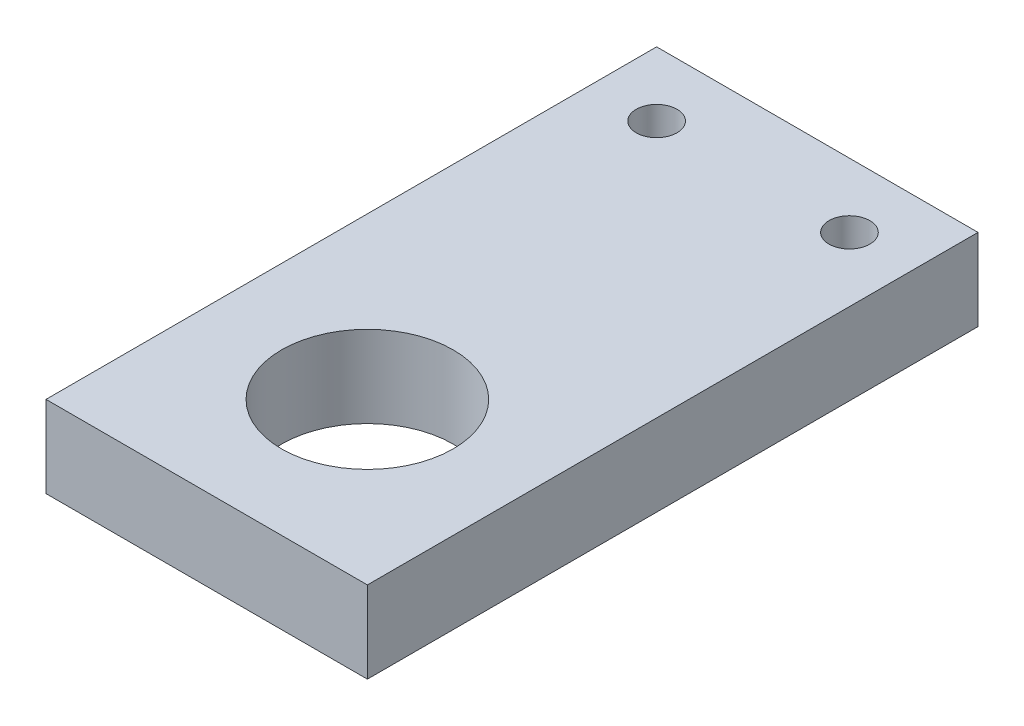
from build123d import *

# Parameters (mm, degrees)
SKETCH1_W           = 25
SKETCH1_H           = 47.5
SKETCH1_R           = 6.675
BOSS_EXTRUDE1_DEPTH = 6.35
CUT_EXTRUDE1_REACH  = 8.35
SKETCH2_R           = 1.5875


with BuildPart() as part:
    # Sketch1 → Boss-Extrude1 (new body)
    with BuildSketch(Plane(origin=(0, 0, 0), x_dir=(1, 0, 0), z_dir=(0, 1, 0))):
        with Locations((12.5, 23.75)):
            Rectangle(SKETCH1_W, SKETCH1_H)
        with Locations((12.5, 12.5)):
            Circle(SKETCH1_R, mode=Mode.SUBTRACT)
    extrude(amount=BOSS_EXTRUDE1_DEPTH)

    # Sketch2 → Cut-Extrude1 (cut, up to next)
    with BuildSketch(Plane(origin=(0, 6.35, 0), x_dir=(1, 0, 0), z_dir=(0, 1, 0)), mode=Mode.PRIVATE) as cut_extrude1_sk1:
        with Locations((20, 42.5)):
            Circle(SKETCH2_R)
    cut_extrude1_tool1 = extrude(cut_extrude1_sk1.sketch, amount=-CUT_EXTRUDE1_REACH, mode=Mode.PRIVATE) & part.part
    add(cut_extrude1_tool1.solids().sort_by_distance((20, 6.35, -42.5))[0], mode=Mode.SUBTRACT)
    # Sketch2 → Cut-Extrude1 (cut, up to next)
    with BuildSketch(Plane(origin=(0, 6.35, 0), x_dir=(1, 0, 0), z_dir=(0, 1, 0)), mode=Mode.PRIVATE) as cut_extrude1_sk2:
        with Locations((5, 42.5)):
            Circle(SKETCH2_R)
    cut_extrude1_tool2 = extrude(cut_extrude1_sk2.sketch, amount=-CUT_EXTRUDE1_REACH, mode=Mode.PRIVATE) & part.part
    add(cut_extrude1_tool2.solids().sort_by_distance((5, 6.35, -42.5))[0], mode=Mode.SUBTRACT)


solid = part.part
